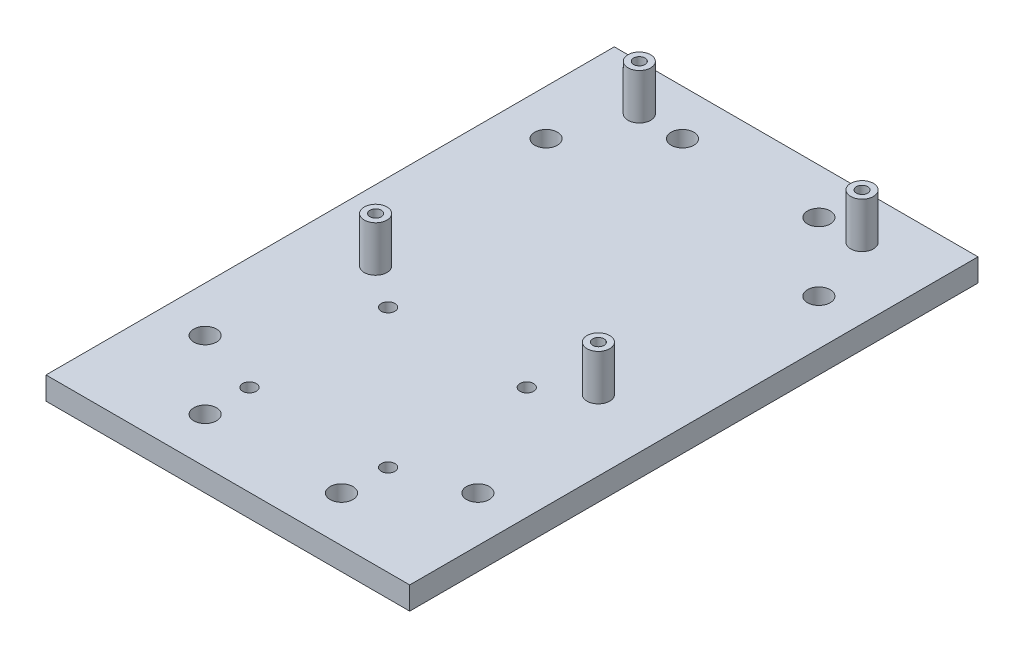
from build123d import *

# Parameters (mm, degrees)
SKETCH1_W           = 80
SKETCH1_H           = 125
SKETCH1_R           = 1.25
SKETCH1_R_2         = 1.5
BOSS_EXTRUDE1_DEPTH = 5
SKETCH2_R           = 2.5
CUT_EXTRUDE1_DEPTH  = 5
SKETCH3_R           = 2.5
SKETCH3_R_2         = 1.25
BOSS_EXTRUDE2_DEPTH = 10


with BuildPart() as part:
    # Sketch1 → Boss-Extrude1 (new body)
    with BuildSketch(Plane(origin=(0, 0, 0), x_dir=(1, 0, 0), z_dir=(0, 1, 0))):
        Rectangle(SKETCH1_W, SKETCH1_H)
        with Locations((-24.5, 52.5)):
            Circle(SKETCH1_R, mode=Mode.SUBTRACT)
        with Locations((24.5, 52.5)):
            Circle(SKETCH1_R, mode=Mode.SUBTRACT)
        with Locations((-24.5, -5.5)):
            Circle(SKETCH1_R, mode=Mode.SUBTRACT)
        with Locations((24.5, -5.5)):
            Circle(SKETCH1_R, mode=Mode.SUBTRACT)
        with Locations((-15.25, -12)):
            Circle(SKETCH1_R_2, mode=Mode.SUBTRACT)
        with Locations((15.25, -12)):
            Circle(SKETCH1_R_2, mode=Mode.SUBTRACT)
        with Locations((-15.25, -42.5)):
            Circle(SKETCH1_R_2, mode=Mode.SUBTRACT)
        with Locations((15.25, -42.5)):
            Circle(SKETCH1_R_2, mode=Mode.SUBTRACT)
    extrude(amount=BOSS_EXTRUDE1_DEPTH)

    # Sketch2 → Cut-Extrude1 (cut)
    with BuildSketch(Plane(origin=(0, 5, 0), x_dir=(1, 0, 0), z_dir=(0, 1, 0))):
        with Locations((-15, 52.5)):
            Circle(SKETCH2_R)
        with Locations((-30, 37.5)):
            Circle(SKETCH2_R)
        with Locations((15, 52.5)):
            Circle(SKETCH2_R)
        with Locations((30, 37.5)):
            Circle(SKETCH2_R)
        with Locations((30, -37.5)):
            Circle(SKETCH2_R)
        with Locations((15, -52.5)):
            Circle(SKETCH2_R)
        with Locations((-15, -52.5)):
            Circle(SKETCH2_R)
        with Locations((-30, -37.5)):
            Circle(SKETCH2_R)
    extrude(amount=-CUT_EXTRUDE1_DEPTH, mode=Mode.SUBTRACT)

    # Sketch3 → Boss-Extrude2 (add)
    with BuildSketch(Plane(origin=(0, 5, 0), x_dir=(1, 0, 0), z_dir=(0, 1, 0))):
        with Locations((-24.5, 52.5)):
            Circle(SKETCH3_R)
        with Locations((-24.5, 52.5)):
            Circle(SKETCH3_R_2, mode=Mode.SUBTRACT)
        with Locations((24.5, 52.5)):
            Circle(SKETCH3_R)
        with Locations((24.5, 52.5)):
            Circle(SKETCH3_R_2, mode=Mode.SUBTRACT)
        with Locations((-24.5, -5.5)):
            Circle(SKETCH3_R)
        with Locations((-24.5, -5.5)):
            Circle(SKETCH3_R_2, mode=Mode.SUBTRACT)
        with Locations((24.5, -5.5)):
            Circle(SKETCH3_R)
        with Locations((24.5, -5.5)):
            Circle(SKETCH3_R_2, mode=Mode.SUBTRACT)
    extrude(amount=BOSS_EXTRUDE2_DEPTH)


solid = part.part
